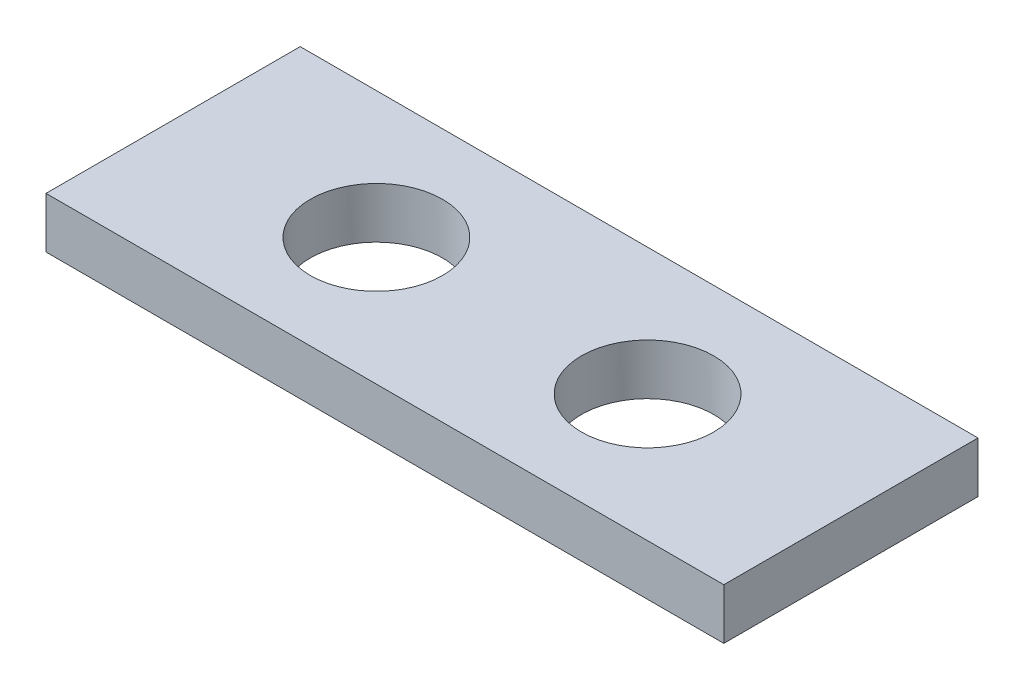
from build123d import *

# Parameters (mm, degrees)
SKETCH1_W           = 40
SKETCH1_H           = 15
BOSS_EXTRUDE1_DEPTH = 3
CUT_EXTRUDE1_START  = -4
SKETCH2_R           = 3.9
CUT_EXTRUDE1_DEPTH  = 5


with BuildPart() as part:
    # Sketch1 → Boss-Extrude1 (new body)
    with BuildSketch(Plane(origin=(0, 0, 0), x_dir=(1, 0, 0), z_dir=(0, 1, 0))):
        Rectangle(SKETCH1_W, SKETCH1_H)
    extrude(amount=BOSS_EXTRUDE1_DEPTH)

    # Sketch2 → Cut-Extrude1 (cut)
    with BuildSketch(Plane(origin=(0, 3, 0), x_dir=(1, 0, 0), z_dir=(0, 1, 0)).offset(CUT_EXTRUDE1_START)):
        with Locations((-8, 0)):
            Circle(SKETCH2_R)
    cut_extrude1 = extrude(amount=CUT_EXTRUDE1_DEPTH, mode=Mode.SUBTRACT)

    # Mirror1: Cut-Extrude1 across plane
    add(cut_extrude1.mirror(Plane(origin=(0, 0, 0), x_dir=(0, 0, 1), z_dir=(1, 0, 0))), mode=Mode.SUBTRACT)


solid = part.part
